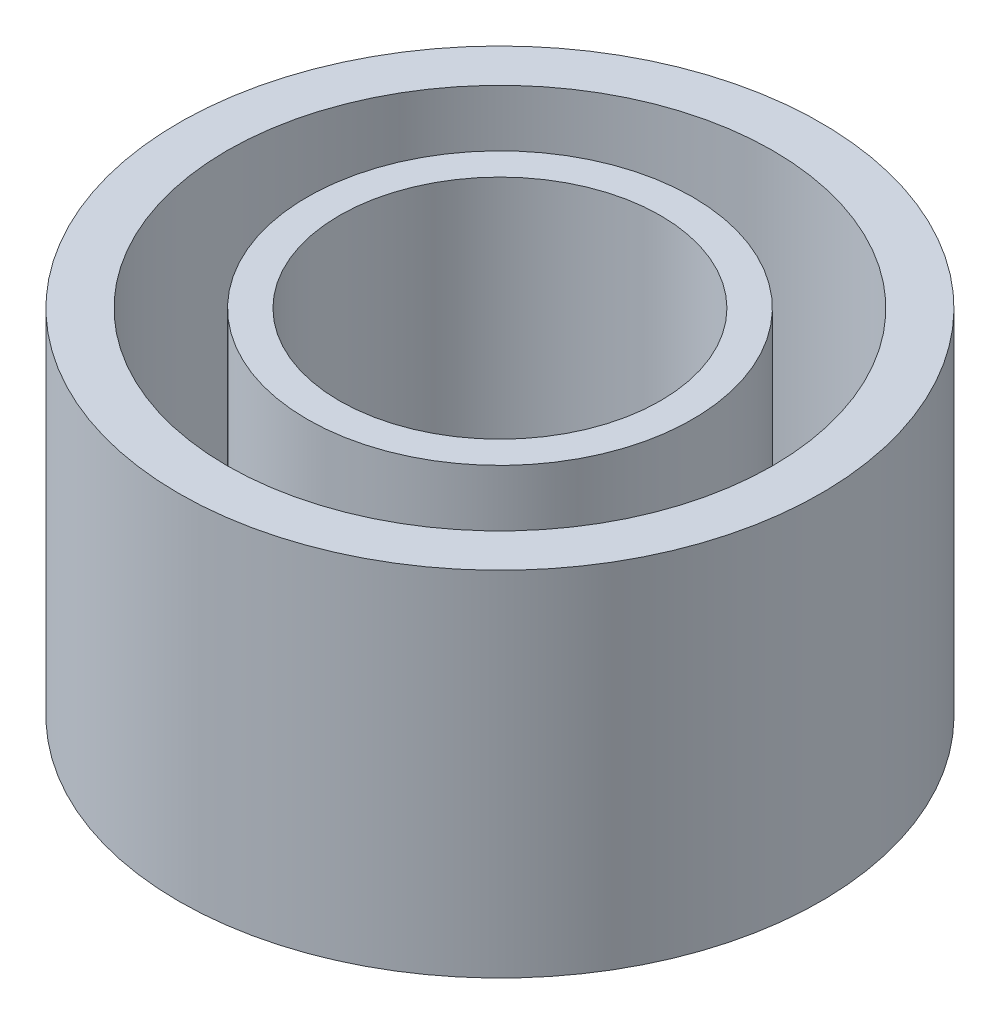
from build123d import *

# Parameters (mm, degrees)
SKETCH1_R           = 10
BOSS_EXTRUDE1_DEPTH = 11
SKETCH2_R           = 8.5
SKETCH2_R_2         = 6
CUT_EXTRUDE1_DEPTH  = 10
SKETCH3_R           = 5
CUT_EXTRUDE2_DEPTH  = 10


with BuildPart() as part:
    # Sketch1 → Boss-Extrude1 (new body)
    with BuildSketch(Plane(origin=(0, 0, 0), x_dir=(1, 0, 0), z_dir=(0, 1, 0))):
        with Locations((-45.043259766, 0)):
            Circle(SKETCH1_R)
    extrude(amount=BOSS_EXTRUDE1_DEPTH)

    # Sketch2 → Cut-Extrude1 (cut)
    with BuildSketch(Plane(origin=(0, 11, 0), x_dir=(1, 0, 0), z_dir=(0, 1, 0))):
        with Locations((-45.043259766, 0)):
            Circle(SKETCH2_R)
        with Locations((-45.043259766, 0)):
            Circle(SKETCH2_R_2, mode=Mode.SUBTRACT)
    extrude(amount=-CUT_EXTRUDE1_DEPTH, mode=Mode.SUBTRACT)

    # Sketch3 → Cut-Extrude2 (cut)
    with BuildSketch(Plane(origin=(0, 11, 0), x_dir=(1, 0, 0), z_dir=(0, 1, 0))):
        with Locations((-45.043259766, 0)):
            Circle(SKETCH3_R)
    extrude(amount=-CUT_EXTRUDE2_DEPTH, mode=Mode.SUBTRACT)


solid = part.part
